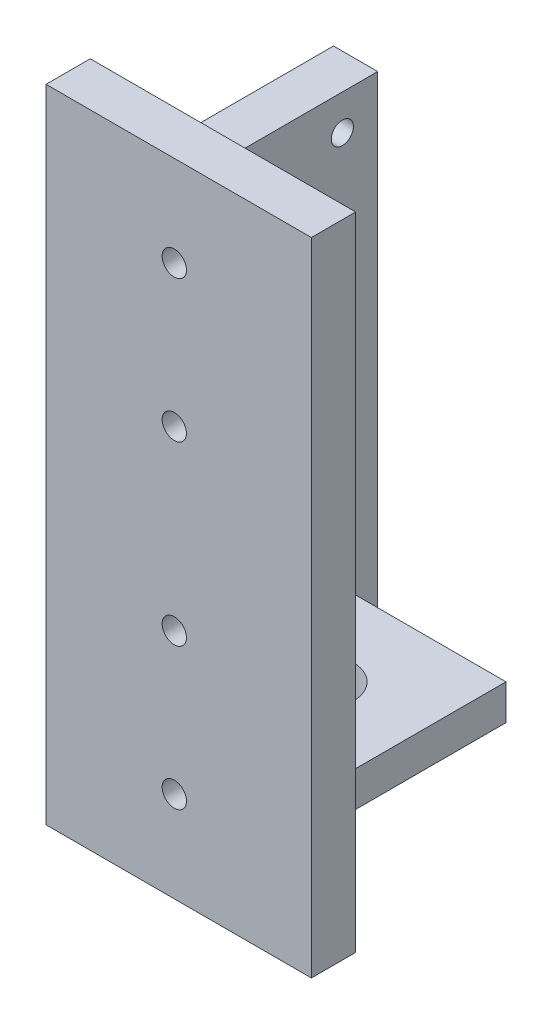
from build123d import *

# Parameters (mm, degrees)
SKETCH1_W           = 10
SKETCH1_H           = 120
BOSS_EXTRUDE1_DEPTH = 55
SKETCH2_W           = 42
SKETCH2_H           = 8
BOSS_EXTRUDE2_DEPTH = 42
SKETCH3_R           = 7.5
CUT_EXTRUDE1_DEPTH  = 8
SKETCH5_W           = 60
SKETCH5_H           = 145
BOSS_EXTRUDE4_DEPTH = 10
SKETCH6_R           = 2.75
CUT_EXTRUDE2_DEPTH  = 10
SKETCH7_R           = 2.5
CUT_EXTRUDE3_DEPTH  = 10


with BuildPart() as part:
    # Sketch1 → Boss-Extrude1 (new body)
    with BuildSketch(Plane.XY):
        with Locations((3, 50.202041029)):
            Rectangle(SKETCH1_W, SKETCH1_H)
    extrude(amount=BOSS_EXTRUDE1_DEPTH)

    # Sketch2 → Boss-Extrude2 (add)
    with BuildSketch(Plane(origin=(8, 0, 0), x_dir=(0, 0, -1), z_dir=(1, 0, 0))):
        with Locations((-34, 14.202041029)):
            Rectangle(SKETCH2_W, SKETCH2_H)
    extrude(amount=BOSS_EXTRUDE2_DEPTH)

    # Sketch3 → Cut-Extrude1 (cut)
    with BuildSketch(Plane.XZ.offset(-10.202041029)):
        with Locations((29, 34)):
            Circle(SKETCH3_R)
    extrude(amount=-CUT_EXTRUDE1_DEPTH, mode=Mode.SUBTRACT)

    # Sketch5 → Boss-Extrude4 (add)
    with BuildSketch(Plane.XY.offset(55)):
        with Locations((28, 62.702041029)):
            Rectangle(SKETCH5_W, SKETCH5_H)
    extrude(amount=BOSS_EXTRUDE4_DEPTH)

    # Sketch6 → Cut-Extrude2 (cut)
    with BuildSketch(Plane.XY.offset(65)):
        with Locations((27, 114.702041029)):
            Circle(SKETCH6_R)
        with Locations((27, 82.702041029)):
            Circle(SKETCH6_R)
        with Locations((27, 42.702041029)):
            Circle(SKETCH6_R)
        with Locations((27, 10.702041029)):
            Circle(SKETCH6_R)
    extrude(amount=-CUT_EXTRUDE2_DEPTH, mode=Mode.SUBTRACT)

    # Sketch7 → Cut-Extrude3 (cut)
    with BuildSketch(Plane(origin=(8, 0, 0), x_dir=(0, 0, -1), z_dir=(1, 0, 0))):
        with Locations((-47, 102.202041029)):
            Circle(SKETCH7_R)
        with Locations((-8, 102.202041029)):
            Circle(SKETCH7_R)
        with Locations((-47, -1.797958971)):
            Circle(SKETCH7_R)
        with Locations((-8, -1.797958971)):
            Circle(SKETCH7_R)
    extrude(amount=-CUT_EXTRUDE3_DEPTH, mode=Mode.SUBTRACT)


solid = part.part
